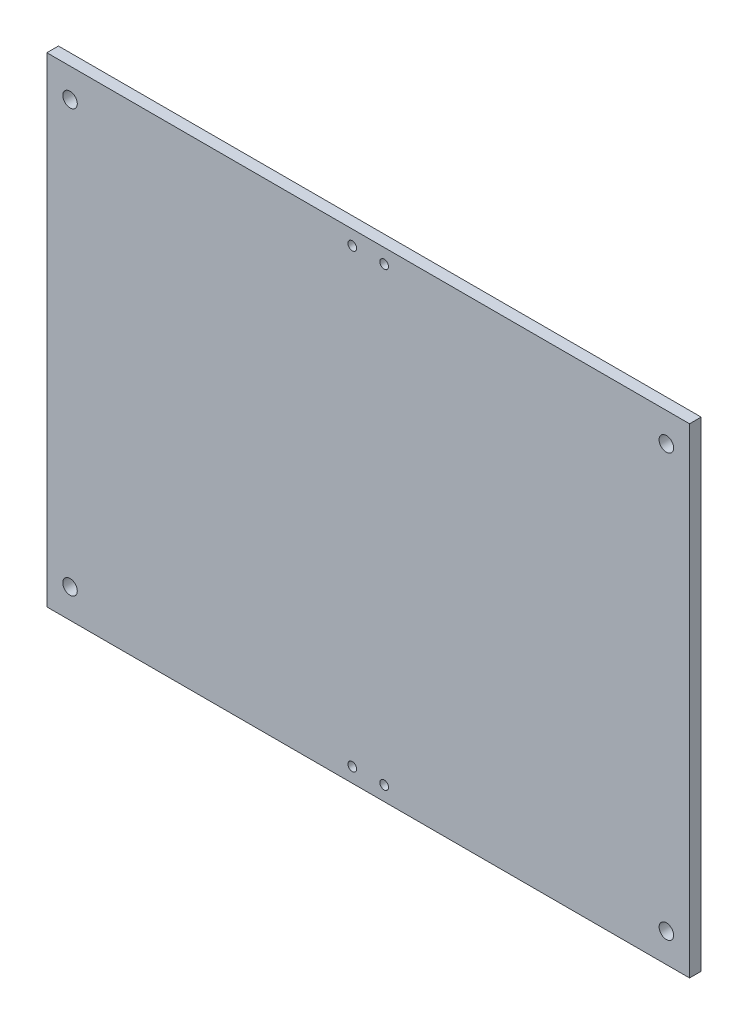
from build123d import *

# Parameters (mm, degrees)
SKETCH1_W           = 221.75
SKETCH1_H           = 165.61
BOSS_EXTRUDE1_DEPTH = 4
SKETCH3_R           = 2.5
CUT_EXTRUDE1_DEPTH  = 5
SKETCH4_R           = 1.5
CUT_EXTRUDE2_DEPTH  = 10


with BuildPart() as part:
    # Sketch1 → Boss-Extrude1 (new body)
    with BuildSketch(Plane.XY):
        with Locations((500.272540984, 348.670409836)):
            Rectangle(SKETCH1_W, SKETCH1_H)
    extrude(amount=BOSS_EXTRUDE1_DEPTH)

    # Sketch3 → Cut-Extrude1 (cut, through all)
    with BuildSketch(Plane.XY.offset(4)):
        with Locations((397.397540984, 421.475409836)):
            Circle(SKETCH3_R)
        with Locations((603.147540984, 421.475409836)):
            Circle(SKETCH3_R)
        with Locations((603.147540984, 275.865409836)):
            Circle(SKETCH3_R)
        with Locations((397.397540984, 275.865409836)):
            Circle(SKETCH3_R)
    extrude(amount=-CUT_EXTRUDE1_DEPTH, mode=Mode.SUBTRACT)

    # Sketch4 → Cut-Extrude2 (cut)
    with BuildSketch(Plane.XY.offset(4)):
        with Locations((494.772540984, 270.865409836)):
            Circle(SKETCH4_R)
        with Locations((505.772540984, 270.865409836)):
            Circle(SKETCH4_R)
        with Locations((494.772540984, 426.475409836)):
            Circle(SKETCH4_R)
        with Locations((505.772540984, 426.475409836)):
            Circle(SKETCH4_R)
    extrude(amount=-CUT_EXTRUDE2_DEPTH, mode=Mode.SUBTRACT)


solid = part.part
